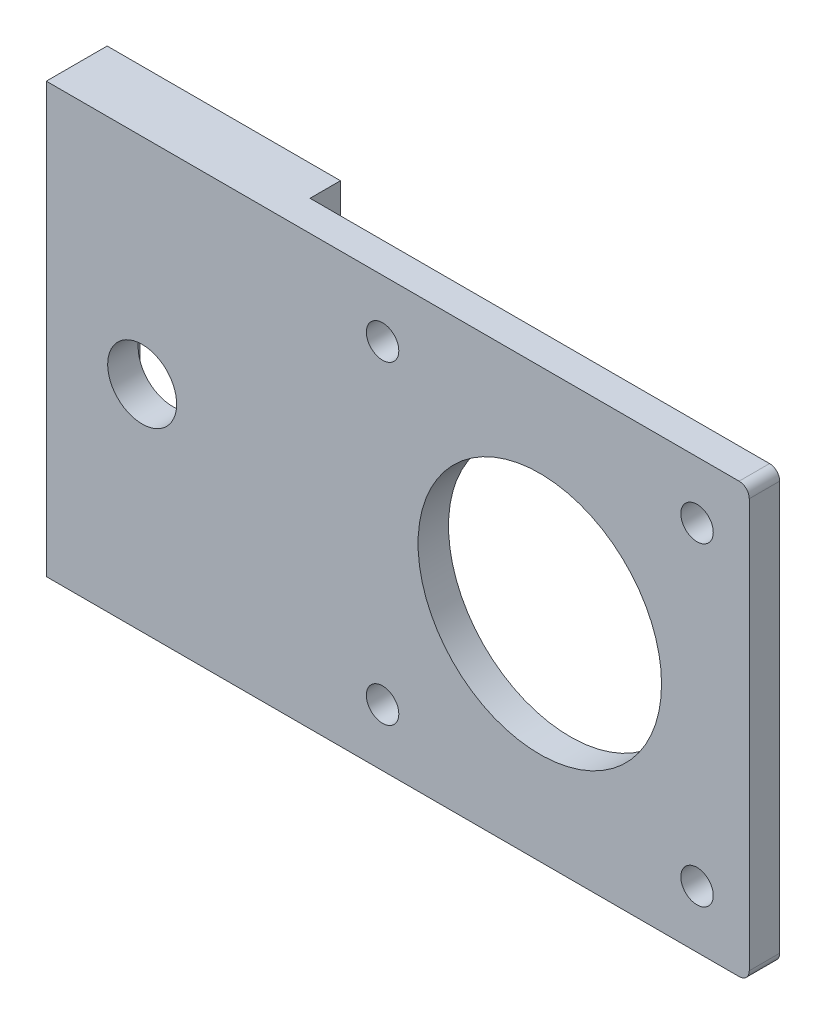
from build123d import *

# Parameters (mm, degrees)
BOSS_EXTRUDE4_DEPTH = 3
SKETCH10_W          = 6
SKETCH10_H          = 42.3
BOSS_EXTRUDE5_DEPTH = 3
SKETCH11_R          = 12
SKETCH11_R_2        = 1.6
CUT_EXTRUDE1_DEPTH  = 7
SKETCH15_W          = 3
SKETCH15_H          = 42.3
BOSS_EXTRUDE8_DEPTH = 20
FILLET5_R           = 1
SKETCH16_R          = 3.4
CUT_EXTRUDE5_DEPTH  = 4
SKETCH23_W          = 20
SKETCH23_H          = 42.3
BOSS_EXTRUDE9_DEPTH = 3
SKETCH26_W          = 12.4
SKETCH26_H          = 13.3
CUT_EXTRUDE7_DEPTH  = 3


with BuildPart() as part:
    # Sketch3 → Boss-Extrude4 (new body)
    with BuildSketch(Plane.XY):
        Polygon((0, 0), (42.3, 0), (42.3, 42.3), (0, 42.3), (-4, 42.3), (-4, 0), align=None)
    extrude(amount=BOSS_EXTRUDE4_DEPTH)

    # Sketch10 → Boss-Extrude5 (add)
    with BuildSketch(Plane.ZY.offset(4)):
        with Locations((0, 21.15)):
            Rectangle(SKETCH10_W, SKETCH10_H)
    extrude(amount=BOSS_EXTRUDE5_DEPTH)

    # Sketch11 → Cut-Extrude1 (cut, through all)
    with BuildSketch(Plane.XY.offset(3)):
        with Locations((21.65, 21.15)):
            Circle(SKETCH11_R)
        with Locations((6.15, 36.65)):
            Circle(SKETCH11_R_2)
        with Locations((37.15, 36.65)):
            Circle(SKETCH11_R_2)
        with Locations((37.15, 5.65)):
            Circle(SKETCH11_R_2)
        with Locations((6.15, 5.65)):
            Circle(SKETCH11_R_2)
    extrude(amount=-CUT_EXTRUDE1_DEPTH, mode=Mode.SUBTRACT)

    # Sketch15 → Boss-Extrude8 (add)
    with BuildSketch(Plane.ZY.offset(7)):
        with Locations((1.5, 21.15)):
            Rectangle(SKETCH15_W, SKETCH15_H)
    extrude(amount=BOSS_EXTRUDE8_DEPTH)

    # Fillet5
    fillet5_edges = [part.edges().sort_by_distance(p)[0] for p in [
        (42.3, 0, 1.5),
        (42.3, 42.3, 1.5),
    ]]
    fillet(fillet5_edges, radius=FILLET5_R)

    # Sketch16 → Cut-Extrude5 (cut, through all)
    with BuildSketch(Plane(origin=(0, 0, 0), x_dir=(-1, 0, 0), z_dir=(0, 0, -1))):
        with Locations((17.55, 21.15)):
            Circle(SKETCH16_R)
    extrude(amount=-CUT_EXTRUDE5_DEPTH, mode=Mode.SUBTRACT)

    # Sketch23 → Boss-Extrude9 (add)
    with BuildSketch(Plane(origin=(0, 0, 0), x_dir=(-1, 0, 0), z_dir=(0, 0, -1))):
        with Locations((17, 21.15)):
            Rectangle(SKETCH23_W, SKETCH23_H)
    extrude(amount=BOSS_EXTRUDE9_DEPTH)

    # Sketch26 → Cut-Extrude7 (cut)
    with BuildSketch(Plane(origin=(0, 0, -3), x_dir=(-1, 0, 0), z_dir=(0, 0, -1))):
        with Locations((17.55, 21.15)):
            Rectangle(SKETCH26_W, SKETCH26_H)
    extrude(amount=-CUT_EXTRUDE7_DEPTH, mode=Mode.SUBTRACT)


solid = part.part
